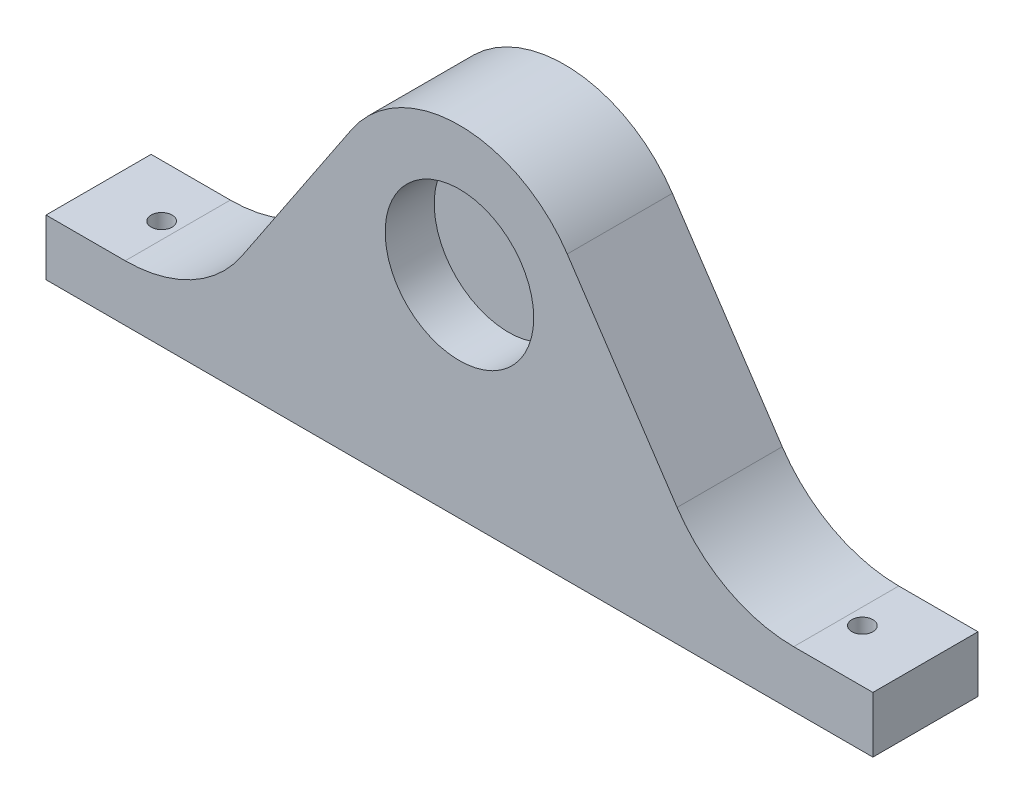
from build123d import *

# Parameters (mm, degrees)
SKETCH4_R           = 10.6
BOSS_EXTRUDE3_DEPTH = 15
SKETCH5_R           = 1.5
CUT_EXTRUDE2_DEPTH  = 15
SKETCH4_2_R         = 10.6
BOSS_EXTRUDE4_DEPTH = 8


with BuildPart() as part:
    # Sketch4 → Boss-Extrude3 (new body)
    with BuildSketch(Plane.XY):
        with BuildLine():
            Line((-59, -30.1), (59, -30.1))
            Line((59, -30.1), (59, -22.100006907))
            Line((59, -22.100006907), (47.694750419, -22.100006907))
            ThreePointArc((47.694750419, -22.100006907), (38.263703272, -19.736768223), (31.061437671, -13.20554188))
            Line((31.061437671, -13.20554188), (15.385814292, 10.27261985))
            ThreePointArc((15.385814292, 10.27261985), (0, 18.5), (-15.385814292, 10.27261985))
            Line((-15.385814292, 10.27261985), (-31.061437671, -13.20554188))
            ThreePointArc((-31.061437671, -13.20554188), (-38.263703272, -19.736768223), (-47.694750419, -22.100006907))
            Line((-47.694750419, -22.100006907), (-59, -22.100006907))
            Line((-59, -22.100006907), (-59, -30.1))
        make_face()
        Circle(SKETCH4_R, mode=Mode.SUBTRACT)
    extrude(amount=BOSS_EXTRUDE3_DEPTH)

    # Sketch5 → Cut-Extrude2 (cut)
    with BuildSketch(Plane.XZ.offset(30.1)):
        with Locations((50, 7.5)):
            Circle(SKETCH5_R)
        with Locations((-50, 7.5)):
            Circle(SKETCH5_R)
    extrude(amount=-CUT_EXTRUDE2_DEPTH, mode=Mode.SUBTRACT)

    # Sketch4_2 → Boss-Extrude4 (add)
    with BuildSketch(Plane.XY):
        Circle(SKETCH4_2_R)
    extrude(amount=BOSS_EXTRUDE4_DEPTH)


solid = part.part
